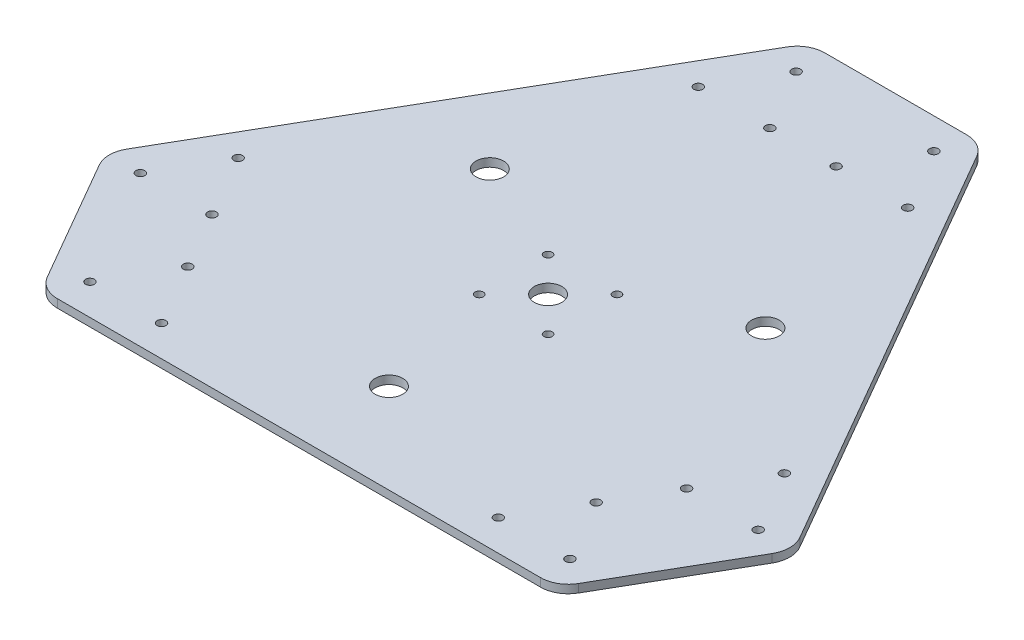
from build123d import *

# Parameters (mm, degrees)
SKETCH1_R           = 1.6
BOSS_EXTRUDE1_DEPTH = 3
SKETCH3_R           = 1.5
SKETCH3_R_2         = 5
CUT_EXTRUDE2_DEPTH  = 4
FILLET1_R           = 10


with BuildPart() as part:
    # Sketch1 → Boss-Extrude1 (new body)
    with BuildSketch(Plane(origin=(0, 0, 0), x_dir=(1, 0, 0), z_dir=(0, 1, 0))):
        Polygon((-31.529631255, 126.118525019), (31.529631255, 126.118525019), (124.986662182, -35.753800871), (93.457030927, -90.364724148), (-93.457030927, -90.364724148), (-124.986662182, -35.753800871), align=None)
        with Locations((-25, 115)):
            Circle(SKETCH1_R, mode=Mode.SUBTRACT)
        with Locations((-12.009618943, 92.5)):
            Circle(SKETCH1_R, mode=Mode.SUBTRACT)
        with Locations((-37.990381057, 92.5)):
            Circle(SKETCH1_R, mode=Mode.SUBTRACT)
        with Locations((37.990381057, 92.5)):
            Circle(SKETCH1_R, mode=Mode.SUBTRACT)
        with Locations((12.009618943, 92.5)):
            Circle(SKETCH1_R, mode=Mode.SUBTRACT)
        with Locations((25, 115)):
            Circle(SKETCH1_R, mode=Mode.SUBTRACT)
        with Locations((112.092921435, -35.849364905)):
            Circle(SKETCH1_R, mode=Mode.SUBTRACT)
        with Locations((86.112159322, -35.849364905)):
            Circle(SKETCH1_R, mode=Mode.SUBTRACT)
        with Locations((99.102540378, -13.349364905)):
            Circle(SKETCH1_R, mode=Mode.SUBTRACT)
        with Locations((74.102540378, -56.650635095)):
            Circle(SKETCH1_R, mode=Mode.SUBTRACT)
        with Locations((87.092921435, -79.150635095)):
            Circle(SKETCH1_R, mode=Mode.SUBTRACT)
        with Locations((61.112159322, -79.150635095)):
            Circle(SKETCH1_R, mode=Mode.SUBTRACT)
        with Locations((-87.092921435, -79.150635095)):
            Circle(SKETCH1_R, mode=Mode.SUBTRACT)
        with Locations((-74.102540378, -56.650635095)):
            Circle(SKETCH1_R, mode=Mode.SUBTRACT)
        with Locations((-61.112159322, -79.150635095)):
            Circle(SKETCH1_R, mode=Mode.SUBTRACT)
        with Locations((-86.112159322, -35.849364905)):
            Circle(SKETCH1_R, mode=Mode.SUBTRACT)
        with Locations((-112.092921435, -35.849364905)):
            Circle(SKETCH1_R, mode=Mode.SUBTRACT)
        with Locations((-99.102540378, -13.349364905)):
            Circle(SKETCH1_R, mode=Mode.SUBTRACT)
    extrude(amount=BOSS_EXTRUDE1_DEPTH)

    # Sketch3 → Cut-Extrude2 (cut, through all)
    with BuildSketch(Plane(origin=(0, 3, 0), x_dir=(1, 0, 0), z_dir=(0, 1, 0))):
        with Locations((-12.5, 12.5)):
            Circle(SKETCH3_R)
        with Locations((12.5, 12.5)):
            Circle(SKETCH3_R)
        with Locations((12.5, -12.5)):
            Circle(SKETCH3_R)
        with Locations((-12.5, -12.5)):
            Circle(SKETCH3_R)
        with Locations((-50, 28.867513459)):
            Circle(SKETCH3_R_2)
        with Locations((50, 28.867513459)):
            Circle(SKETCH3_R_2)
        with Locations((0, -57.735026919)):
            Circle(SKETCH3_R_2)
        Circle(SKETCH3_R_2)
    extrude(amount=-CUT_EXTRUDE2_DEPTH, mode=Mode.SUBTRACT)

    # Fillet1
    fillet1_edges = [part.edges().sort_by_distance(p)[0] for p in [
        (-31.529631255, 1.5, -126.118525019),
        (31.529631255, 1.5, -126.118525019),
        (124.986662182, 1.5, 35.753800871),
        (93.457030927, 1.5, 90.364724148),
        (-93.457030927, 1.5, 90.364724148),
        (-124.986662182, 1.5, 35.753800871),
    ]]
    fillet(fillet1_edges, radius=FILLET1_R)


solid = part.part
